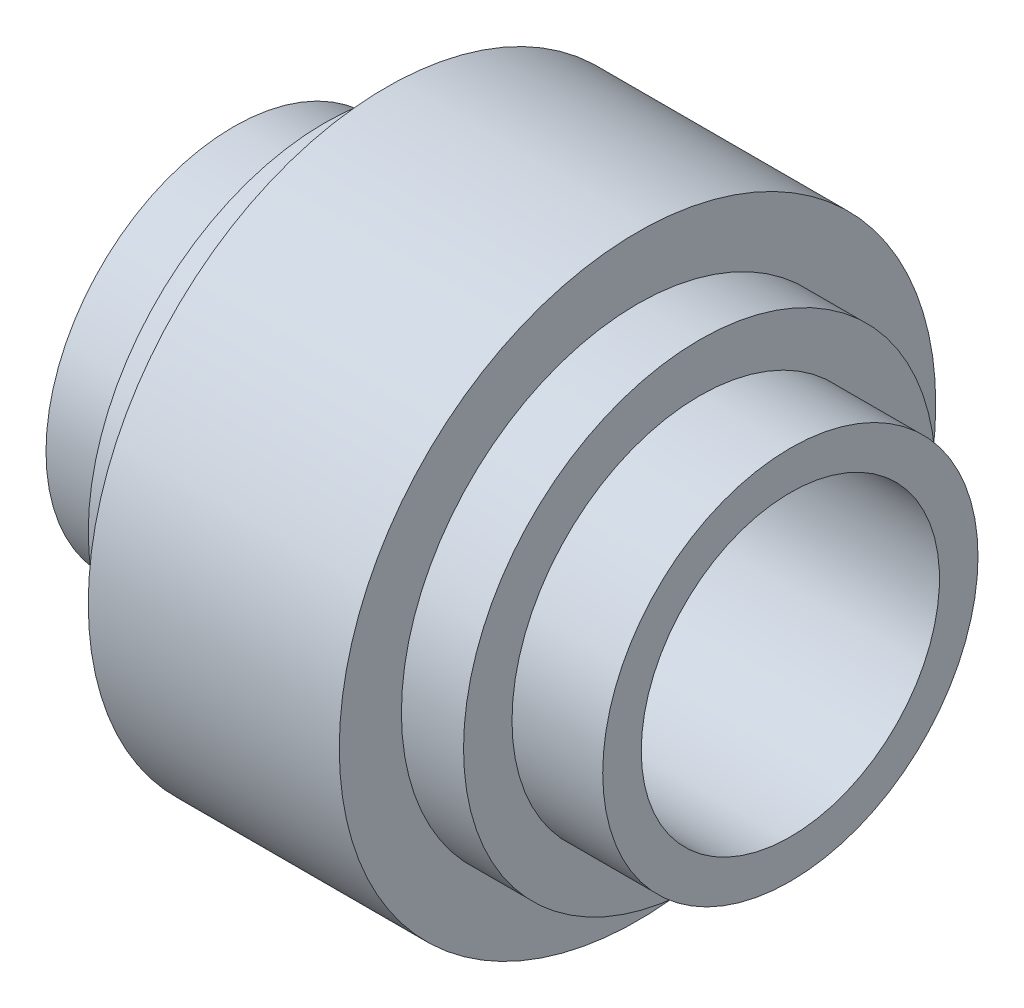
from build123d import *


with BuildPart() as part:
    # Sketch1 → Revolve1 (revolve)
    with BuildSketch(Plane.XY):
        Polygon((81.25, 47.5), (93.75, 47.5), (93.75, 37.75), (112, 37.75), (112, 30), (0, 30), (0, 37.75), (18.25, 37.75), (18.25, 47.5), (30.75, 47.5), (30.75, 60), (81.25, 60), align=None)
    revolve(axis=Axis((0, 0, 0), (1, 0, 0)))


solid = part.part
